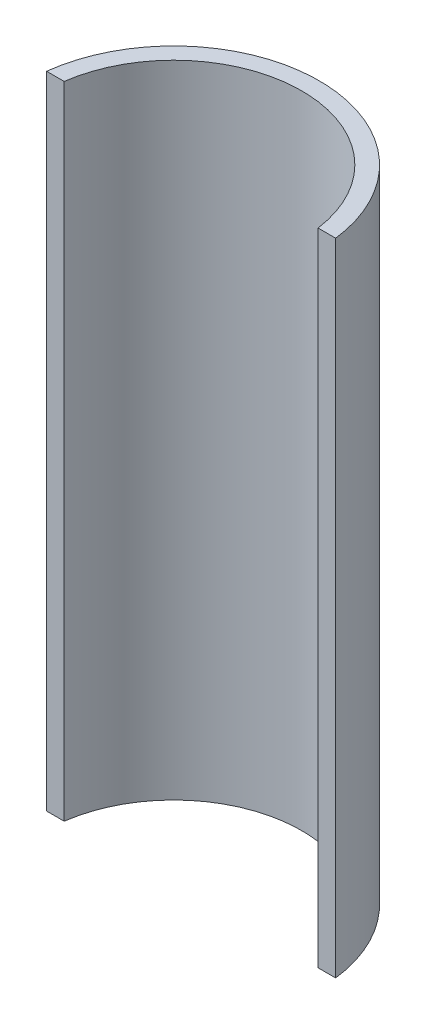
from build123d import *

# Parameters (mm, degrees)
BOSS_EXTRUDE1_DEPTH = 55


with BuildPart() as part:
    # Sketch1 → Boss-Extrude1 (new body, symmetric)
    with BuildSketch(Plane(origin=(0, 0, 0), x_dir=(1, 0, 0), z_dir=(0, 1, 0))):
        with BuildLine():
            Line((-24.819347292, 3), (-21.794494718, 3))
            ThreePointArc((-21.794494718, 3), (0, 22), (21.794494718, 3))
            Line((21.794494718, 3), (24.819347292, 3))
            ThreePointArc((24.819347292, 3), (0, 25), (-24.819347292, 3))
        make_face()
    extrude(amount=BOSS_EXTRUDE1_DEPTH, both=True)


solid = part.part
